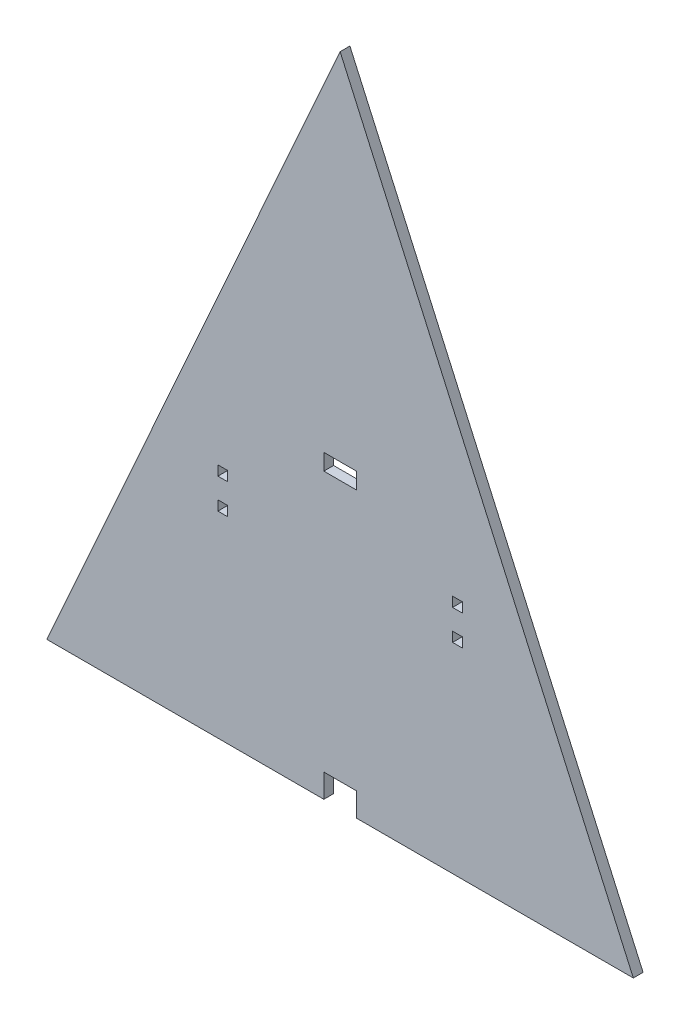
from build123d import *

# Parameters (mm, degrees)
SKETCH1_W           = 3
SKETCH1_H           = 3
SKETCH1_W_2         = 10
SKETCH1_H_2         = 5
BOSS_EXTRUDE4_DEPTH = 3


with BuildPart() as part:
    # Sketch1 → Boss-Extrude4 (new body)
    with BuildSketch(Plane.XY):
        Polygon((90, 201.25), (0, 0), (85, 0), (85, 7.26), (95, 7.26), (95, 0), (180, 0), align=None)
        with Locations((53.99, 61.857444444)):
            Rectangle(SKETCH1_W, SKETCH1_H, mode=Mode.SUBTRACT)
        with Locations((53.99, 71.157444444)):
            Rectangle(SKETCH1_W, SKETCH1_H, mode=Mode.SUBTRACT)
        with Locations((90, 89.737444444)):
            Rectangle(SKETCH1_W_2, SKETCH1_H_2, mode=Mode.SUBTRACT)
        with Locations((126.01, 62.967444444)):
            Rectangle(SKETCH1_W, SKETCH1_H, mode=Mode.SUBTRACT)
        with Locations((126.01, 72.267444444)):
            Rectangle(SKETCH1_W, SKETCH1_H, mode=Mode.SUBTRACT)
    extrude(amount=BOSS_EXTRUDE4_DEPTH)


solid = part.part
